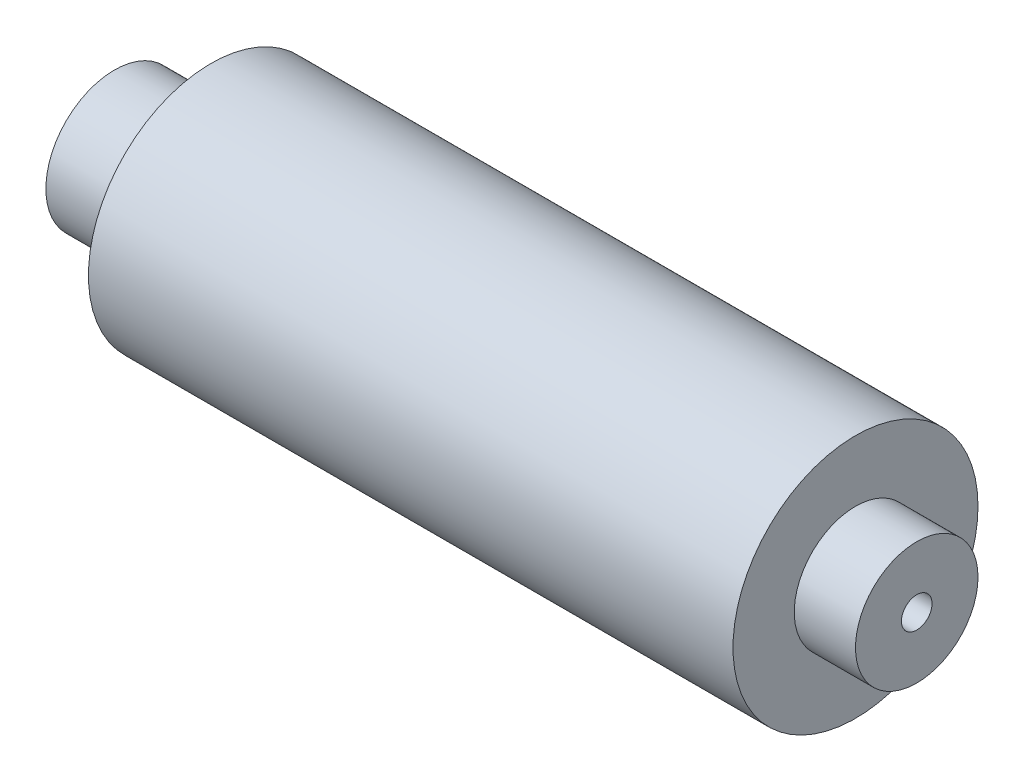
from build123d import *


with BuildPart() as part:
    # Sketch2 → Revolve1 (revolve)
    with BuildSketch(Plane(origin=(0, 0, 0), x_dir=(1, 0, 0), z_dir=(0, 1, 0))):
        Polygon((0, 2.38125), (0, 3.556), (5, 3.556), (5, 6.35), (38.4125, 6.35), (38.4125, 3.175), (41.5875, 3.175), (41.5875, 0.79375), (11.5875, 0.79375), (10, 2.38125), align=None)
    revolve(axis=Axis((0, 0, 0), (-1, 0, 0)))


solid = part.part
